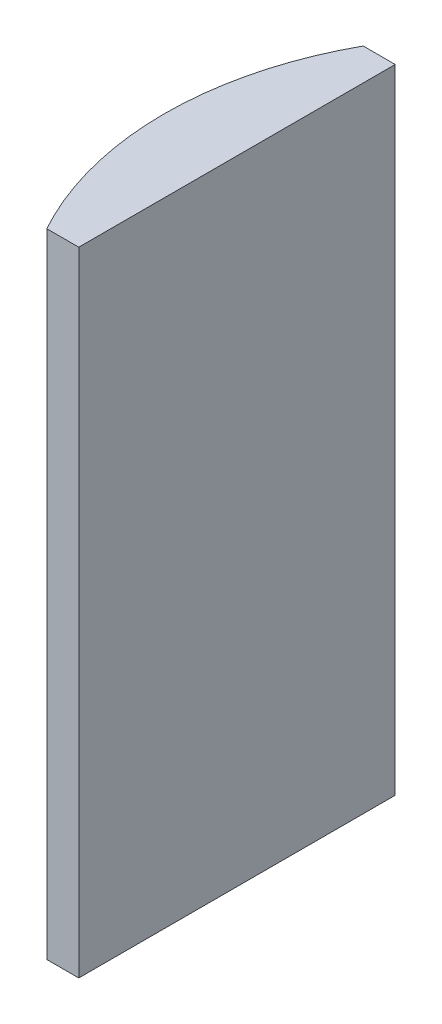
from build123d import *

# Parameters (mm, degrees)
EXTRUDE_1_DEPTH = 40


with BuildPart() as part:
    # 草图1 → 凸台-拉伸1 (new body)
    with BuildSketch(Plane(origin=(0, 0, 0), x_dir=(1, 0, 0), z_dir=(0, 1, 0))):
        with BuildLine():
            Line((-13.746243121, 10), (-11.724795665, 10))
            Line((-11.724795665, 10), (-11.724795665, -10))
            Line((-11.724795665, -10), (-13.746243121, -10))
            ThreePointArc((-13.746243121, -10), (-16.324795665, 0), (-13.746243121, 10))
        make_face()
    extrude(amount=EXTRUDE_1_DEPTH)


solid = part.part
